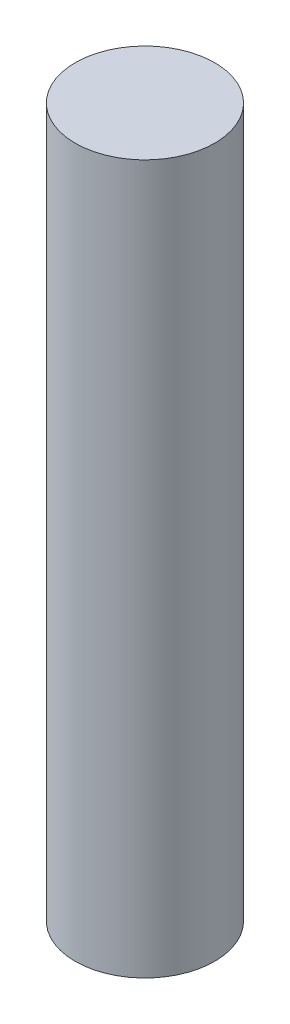
from build123d import *

# Parameters (mm, degrees)
SKETCH_1_R      = 9.45
EXTRUDE_1_DEPTH = 96


with BuildPart() as part:
    # 스케치1 → 보스-돌출1 (new body)
    with BuildSketch(Plane(origin=(0, 0, 0), x_dir=(1, 0, 0), z_dir=(0, 1, 0))):
        Circle(SKETCH_1_R)
    extrude(amount=EXTRUDE_1_DEPTH)


solid = part.part
